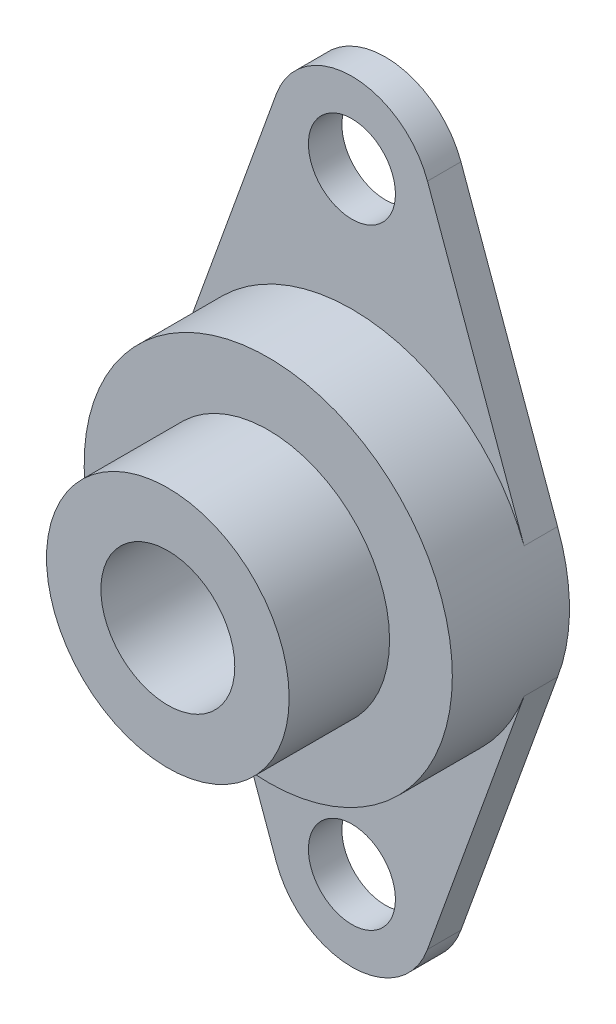
from build123d import *

# Parameters (mm, degrees)
CROQUIS1_R              = 4
CROQUIS1_R_2            = 2.6
SALIENTE_EXTRUIR1_DEPTH = 7
CROQUIS2_R              = 2.6
CORTAR_EXTRUIR1_DEPTH   = 5
CROQUIS3_R              = 7.25
CROQUIS3_R_2            = 4
SALIENTE_EXTRUIR2_DEPTH = 6


with BuildPart() as part:
    # Croquis1 → Saliente-Extruir1 (new body)
    with BuildSketch(Plane.XY):
        with BuildLine():
            Line((10.288824315, -3.891027397), (4.514634908, -19.880359362))
            ThreePointArc((4.514634908, -19.880359362), (0, -23.05), (-4.514634908, -19.880359362))
            Line((-4.514634908, -19.880359362), (-10.288824315, -3.891027397))
            ThreePointArc((-10.288824315, -3.891027397), (-11, 0), (-10.288824315, 3.891027397))
            Line((-10.288824315, 3.891027397), (-4.514634908, 19.880359362))
            ThreePointArc((-4.514634908, 19.880359362), (0, 23.05), (4.514634908, 19.880359362))
            Line((4.514634908, 19.880359362), (10.288824315, 3.891027397))
            ThreePointArc((10.288824315, 3.891027397), (11, 0), (10.288824315, -3.891027397))
        make_face()
        Circle(CROQUIS1_R, mode=Mode.SUBTRACT)
        with Locations((0, 18.25)):
            Circle(CROQUIS1_R_2, mode=Mode.SUBTRACT)
        with Locations((0, -18.25)):
            Circle(CROQUIS1_R_2, mode=Mode.SUBTRACT)
    extrude(amount=SALIENTE_EXTRUIR1_DEPTH)

    # Croquis2 → Cortar-Extruir1 (cut)
    with BuildSketch(Plane.XY.offset(7)):
        with BuildLine():
            Line((-4.514634908, 19.880359362), (-10.288824315, 3.891027397))
            ThreePointArc((-10.288824315, 3.891027397), (0, 11), (10.288824315, 3.891027397))
            Line((10.288824315, 3.891027397), (4.514634908, 19.880359362))
            ThreePointArc((4.514634908, 19.880359362), (0, 23.05), (-4.514634908, 19.880359362))
        make_face()
        with Locations((0, 18.25)):
            Circle(CROQUIS2_R, mode=Mode.SUBTRACT)
        with BuildLine():
            ThreePointArc((10.288824315, -3.891027397), (0, -11), (-10.288824315, -3.891027397))
            Line((-10.288824315, -3.891027397), (-4.514634908, -19.880359362))
            ThreePointArc((-4.514634908, -19.880359362), (0, -23.05), (4.514634908, -19.880359362))
            Line((4.514634908, -19.880359362), (10.288824315, -3.891027397))
        make_face()
        with Locations((0, -18.25)):
            Circle(CROQUIS2_R, mode=Mode.SUBTRACT)
    extrude(amount=-CORTAR_EXTRUIR1_DEPTH, mode=Mode.SUBTRACT)

    # Croquis3 → Saliente-Extruir2 (add)
    with BuildSketch(Plane.XY.offset(7)):
        Circle(CROQUIS3_R)
        Circle(CROQUIS3_R_2, mode=Mode.SUBTRACT)
    extrude(amount=SALIENTE_EXTRUIR2_DEPTH)


solid = part.part
